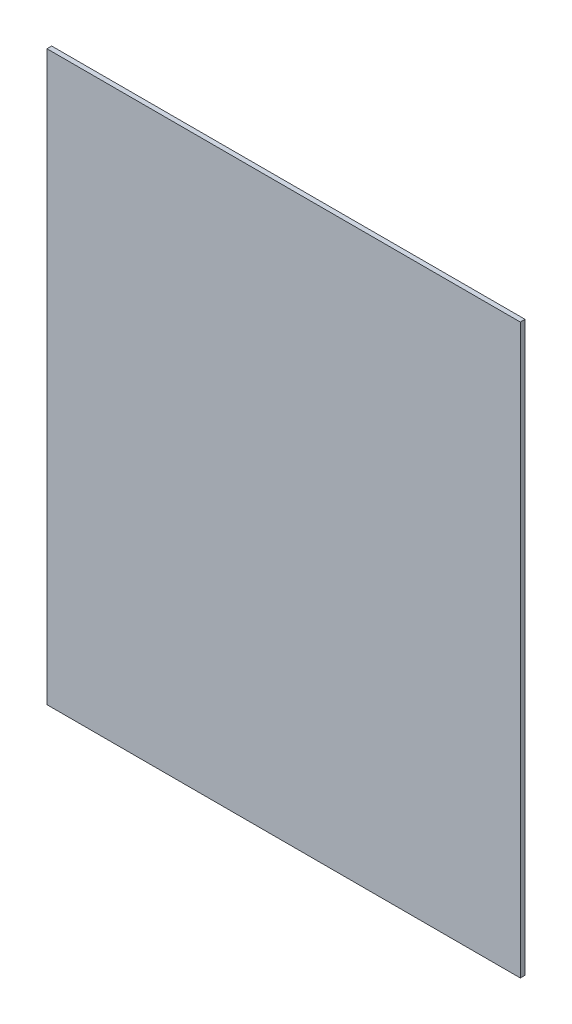
from build123d import *

# Parameters (mm, degrees)
CROQUIS1_W              = 500
CROQUIS1_H              = 600
SALIENTE_EXTRUIR1_DEPTH = 5


with BuildPart() as part:
    # Croquis1 → Saliente-Extruir1 (new body)
    with BuildSketch(Plane.XY):
        Rectangle(CROQUIS1_W, CROQUIS1_H)
    extrude(amount=SALIENTE_EXTRUIR1_DEPTH)


solid = part.part
